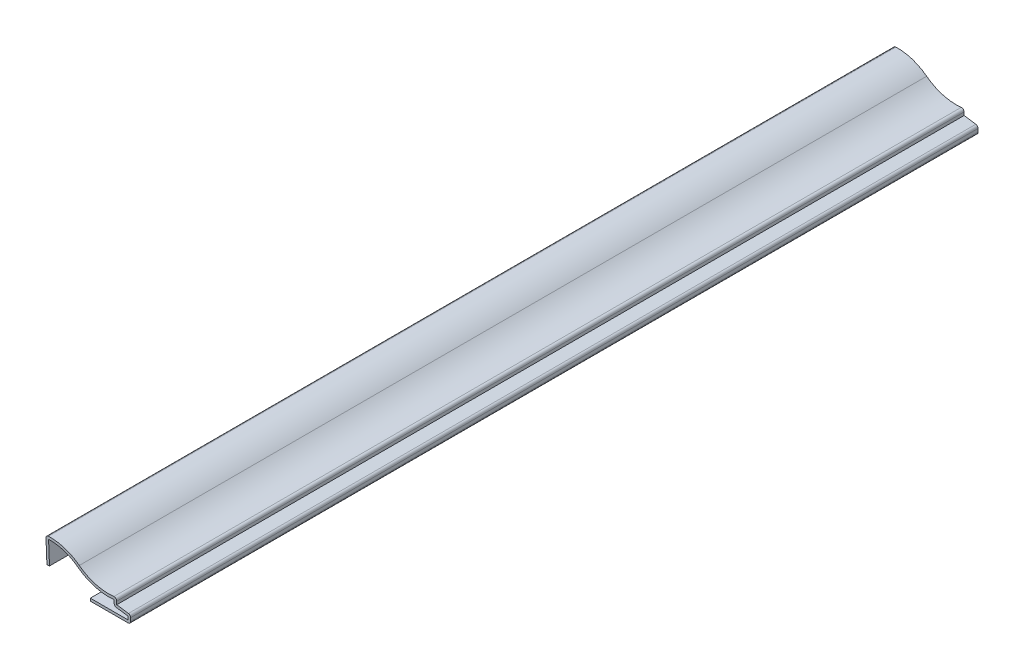
from build123d import *

# Parameters (mm, degrees)
EXTRUDE_THIN1_DEPTH = 333.375
FILLET1_R           = 1.016


with BuildPart() as part:
    # Sketch1 → Extrude-Thin1 (new body)
    with BuildSketch(Plane.XY):
        with BuildLine():
            Line((0, 0), (-0.396875, 9.921875))
            ThreePointArc((-0.396875, 9.921875), (6.530313151, 9.224476066), (12.744287778, 6.084600226))
            ThreePointArc((12.744287778, 6.084600226), (19.730938199, 2.736608506), (27.472950555, 2.44751107))
            Line((27.472950555, 2.44751107), (27.472950555, 0.06626107))
            Line((27.472950555, 0.06626107), (32.940625, -0.72748893))
            Line((32.940625, -0.72748893), (32.940625, -3.90248893))
            Line((32.940625, -3.90248893), (17.065625, -3.90248893))
            Line((17.065625, -3.90248893), (17.065625, -2.88648893))
            Line((17.065625, -2.88648893), (31.924625, -2.88648893))
            Line((31.924625, -2.88648893), (31.924625, -1.606644926))
            Line((31.924625, -1.606644926), (26.456950555, -0.812894926))
            Line((26.456950555, -0.812894926), (26.456950555, 1.28155123))
            ThreePointArc((26.456950555, 1.28155123), (18.908627692, 1.902340806), (12.12809243, 5.276788804))
            ThreePointArc((12.12809243, 5.276788804), (6.71021132, 8.106692295), (0.658241432, 8.964276082))
            Line((0.658241432, 8.964276082), (1.015188174, 0.040607527))
            Line((1.015188174, 0.040607527), (0, 0))
        make_face()
    extrude(amount=-EXTRUDE_THIN1_DEPTH)

    # Fillet1
    fillet1_edges = [part.edges().sort_by_distance(p)[0] for p in [
        (26.456950555, -0.812894926, -166.6875),
        (-0.396875, 9.921875, -166.6875),
        (27.472950555, 2.44751107, -166.6875),
        (32.940625, -0.72748893, -166.6875),
        (32.940625, -3.90248893, -166.6875),
    ]]
    fillet(fillet1_edges, radius=FILLET1_R)


solid = part.part
